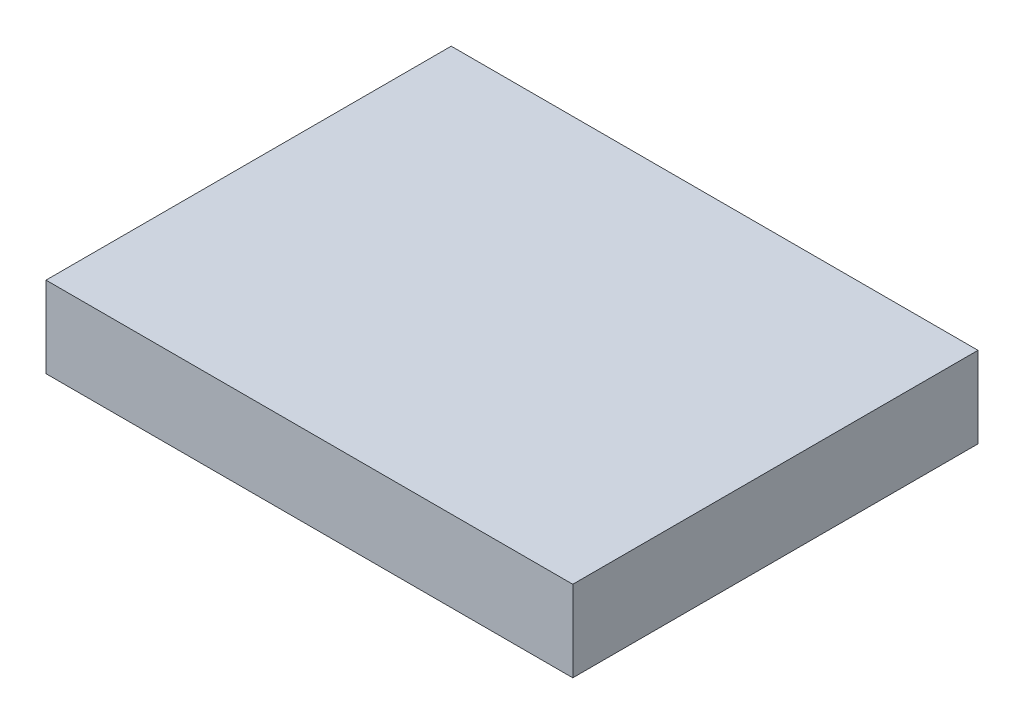
from build123d import *

# Parameters (mm, degrees)
RESSALTO_EXTRUS_O1_DEPTH      = 10
RESSALTO_EXTRUS_O1_DEPTH_BACK = 10
ESBO_O1_W                     = 130
ESBO_O1_H                     = 100


with BuildPart() as part:
    # Esboço1 → Ressalto-extrusão1 (new, two sides: drawn at the far end of the back side and taken through both)
    with BuildSketch(Plane(origin=(0, 0, 0), x_dir=(1, 0, 0), z_dir=(0, 1, 0)).offset(-RESSALTO_EXTRUS_O1_DEPTH_BACK)):
        with Locations((15.194480663, 0)):
            Rectangle(ESBO_O1_W, ESBO_O1_H)
    extrude(amount=RESSALTO_EXTRUS_O1_DEPTH + RESSALTO_EXTRUS_O1_DEPTH_BACK)


solid = part.part
